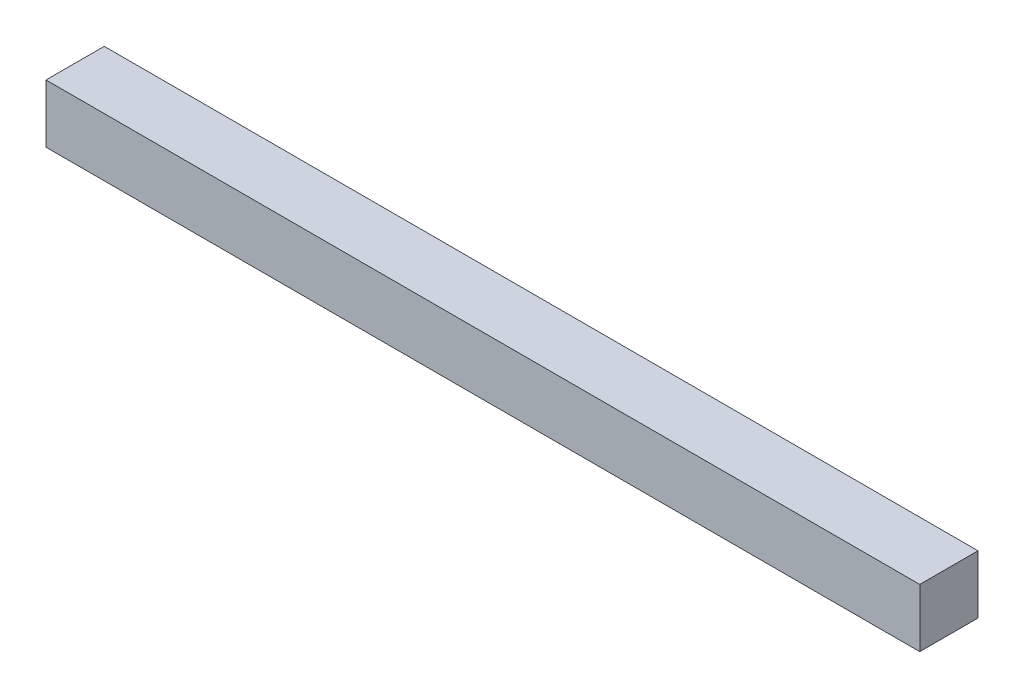
from build123d import *

# Parameters (mm, degrees)
SKETCH1_W           = 762
SKETCH1_H           = 50.8
BOSS_EXTRUDE1_DEPTH = 50.8


with BuildPart() as part:
    # Sketch1 → Boss-Extrude1 (new body)
    with BuildSketch(Plane.XY):
        Rectangle(SKETCH1_W, SKETCH1_H)
    extrude(amount=BOSS_EXTRUDE1_DEPTH)


solid = part.part
